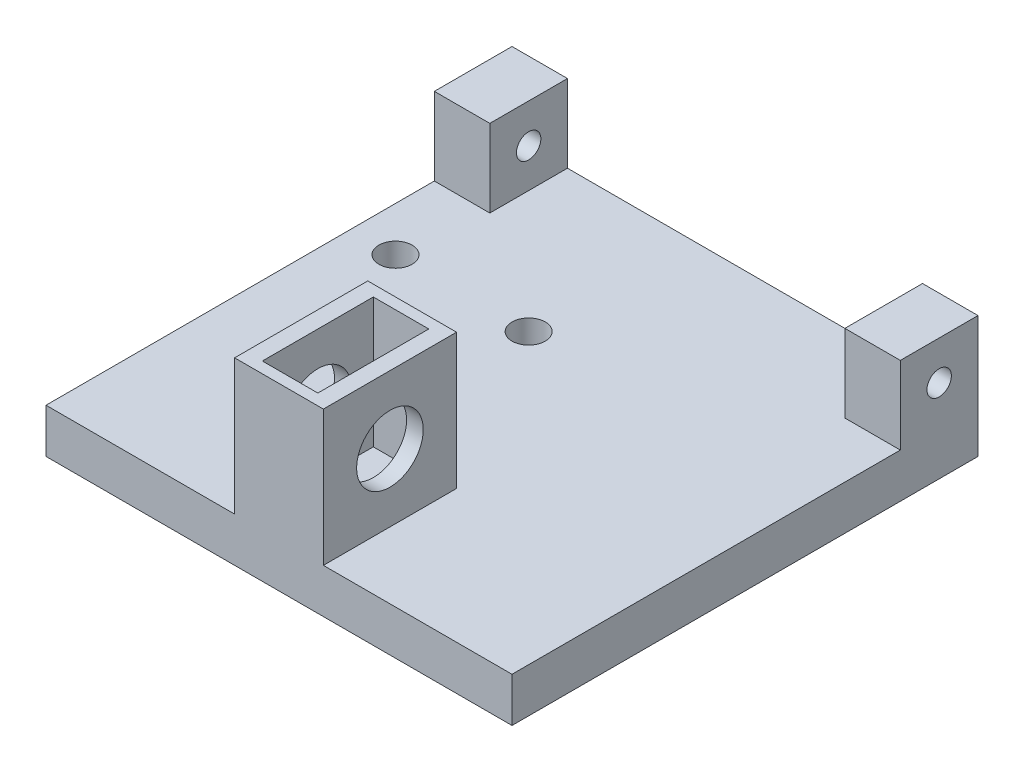
from build123d import *

# Parameters (mm, degrees)
SKETCH2_W           = 42
SKETCH2_H           = 42
BOSS_EXTRUDE1_DEPTH = 4
SKETCH4_W           = 5
SKETCH4_H           = 7
BOSS_EXTRUDE2_DEPTH = 7
SKETCH5_R           = 1.1
CUT_EXTRUDE2_DEPTH  = 5
SKETCH6_R           = 1.1
CUT_EXTRUDE3_DEPTH  = 5
SKETCH8_R           = 1.5
CUT_EXTRUDE5_DEPTH  = 4
SKETCH9_W           = 8
SKETCH9_H           = 12
BOSS_EXTRUDE3_DEPTH = 12.2
SKETCH10_W          = 5
SKETCH10_H          = 10
CUT_EXTRUDE6_DEPTH  = 11.7
SKETCH12_R          = 3
CUT_EXTRUDE7_DEPTH  = 8


with BuildPart() as part:
    # Sketch2 → Boss-Extrude1 (new body)
    with BuildSketch(Plane(origin=(0, 0, 0), x_dir=(1, 0, 0), z_dir=(0, 1, 0))):
        with Locations((-19.403711124, 0.667809886)):
            Rectangle(SKETCH2_W, SKETCH2_H)
    extrude(amount=BOSS_EXTRUDE1_DEPTH)

    # Sketch4 → Boss-Extrude2 (add)
    with BuildSketch(Plane(origin=(0, 4, 0), x_dir=(1, 0, 0), z_dir=(0, 1, 0))):
        with Locations((-37.903711124, 18.167809886)):
            Rectangle(SKETCH4_W, SKETCH4_H)
        with Locations((-0.903711124, 18.167809886)):
            Rectangle(SKETCH4_W, SKETCH4_H)
    extrude(amount=BOSS_EXTRUDE2_DEPTH)

    # Sketch5 → Cut-Extrude2 (cut)
    with BuildSketch(Plane(origin=(-35.403711124, 0, 0), x_dir=(0, 0, -1), z_dir=(1, 0, 0))):
        with Locations((18.167809886, 7.5)):
            Circle(SKETCH5_R)
    extrude(amount=-CUT_EXTRUDE2_DEPTH, mode=Mode.SUBTRACT)

    # Sketch6 → Cut-Extrude3 (cut)
    with BuildSketch(Plane.ZY.offset(3.403711124)):
        with Locations((-18.167809886, 7.5)):
            Circle(SKETCH6_R)
    extrude(amount=-CUT_EXTRUDE3_DEPTH, mode=Mode.SUBTRACT)

    # Sketch8 → Cut-Extrude5 (cut)
    with BuildSketch(Plane.XZ):
        with Locations((-36.403711124, -7.167809886)):
            Circle(SKETCH8_R)
        with Locations((-24.403711124, -7.167809886)):
            Circle(SKETCH8_R)
    extrude(amount=-CUT_EXTRUDE5_DEPTH, mode=Mode.SUBTRACT)

    # Sketch9 → Boss-Extrude3 (add)
    with BuildSketch(Plane(origin=(0, 4, 0), x_dir=(1, 0, 0), z_dir=(0, 1, 0))):
        with Locations((-19.403711124, -14.332190114)):
            Rectangle(SKETCH9_W, SKETCH9_H)
    extrude(amount=BOSS_EXTRUDE3_DEPTH)

    # Sketch10 → Cut-Extrude6 (cut)
    with BuildSketch(Plane(origin=(0, 16.2, 0), x_dir=(1, 0, 0), z_dir=(0, 1, 0))):
        with Locations((-19.403711124, -14.332190114)):
            Rectangle(SKETCH10_W, SKETCH10_H)
    extrude(amount=-CUT_EXTRUDE6_DEPTH, mode=Mode.SUBTRACT)

    # Sketch12 → Cut-Extrude7 (cut)
    with BuildSketch(Plane(origin=(-15.403711124, 0, 0), x_dir=(0, 0, -1), z_dir=(1, 0, 0))):
        with Locations((-14.332190114, 10.1)):
            Circle(SKETCH12_R)
    extrude(amount=-CUT_EXTRUDE7_DEPTH, mode=Mode.SUBTRACT)


solid = part.part
